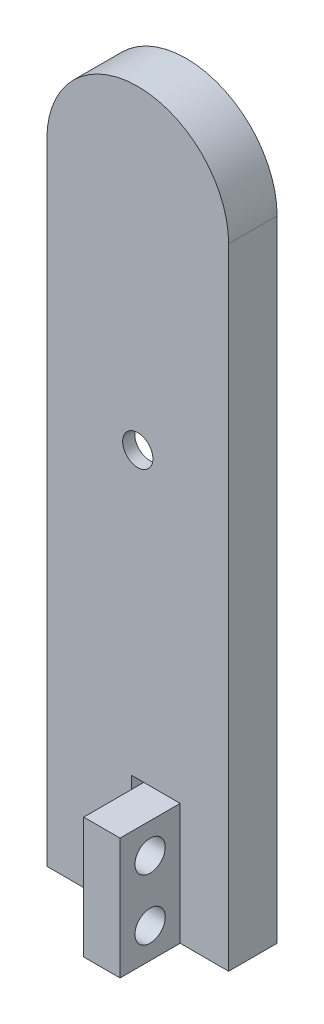
from build123d import *

# Parameters (mm, degrees)
EXTRUDE_1_DEPTH     = 4
CUT_EXTRUDE_1_DEPTH = 3
SKETCH_5_R          = 1.25
CUT_EXTRUDE_2_DEPTH = 12.4
SKETCH_6_W          = 1
SKETCH_6_H          = 10
CUT_EXTRUDE_3_DEPTH = 16.3
SKETCH_9_W          = 5
SKETCH_9_H          = 10
EXTRUDE_4_DEPTH     = 3
SKETCH_10_R         = 1.25
CUT_EXTRUDE_4_DEPTH = 5.1


with BuildPart() as part:
    # 草圖1 → 填料-伸長1 (new body)
    with BuildSketch(Plane.XY):
        with BuildLine():
            Line((7.5, 0), (7.5, 52))
            ThreePointArc((7.5, 52), (0, 59.5), (-7.5, 52))
            Line((-7.5, 52), (-7.5, 0))
            Line((-7.5, 0), (7.5, 0))
        make_face()
    extrude(amount=EXTRUDE_1_DEPTH)

    # 草圖3 → 除料-伸長1 (cut)
    with BuildSketch(Plane.XY):
        with BuildLine():
            ThreePointArc((-2.5, 48.75876512), (0, 51.25876512), (2.5, 48.75876512))
            Line((2.5, 48.75876512), (5, 33.5))
            Line((5, 33.5), (2.467939071, 17.842139978))
            ThreePointArc((2.467939071, 17.842139978), (-0.200190311, 15.749263002), (-2.5, 18.24123488))
            Line((-2.5, 18.24123488), (-5, 33.5))
            Line((-5, 33.5), (-2.5, 48.75876512))
        make_face()
    extrude(amount=CUT_EXTRUDE_1_DEPTH, mode=Mode.SUBTRACT)

    # 草圖5 → 除料-伸長2 (cut)
    with BuildSketch(Plane.XY):
        with Locations((0, 33.5)):
            Circle(SKETCH_5_R)
    extrude(amount=CUT_EXTRUDE_2_DEPTH, mode=Mode.SUBTRACT)

    # 草圖6 → 除料-伸長3 (cut)
    with BuildSketch(Plane.XY):
        with Locations((0, 5)):
            Rectangle(SKETCH_6_W, SKETCH_6_H)
    extrude(amount=CUT_EXTRUDE_3_DEPTH, mode=Mode.SUBTRACT)

    # 草圖9 → 填料-伸長4 (add)
    with BuildSketch(Plane(origin=(0.5, 0, 0), x_dir=(0, 0, -1), z_dir=(1, 0, 0))):
        with Locations((-6.46178466, 5)):
            Rectangle(SKETCH_9_W, SKETCH_9_H)
    extrude(amount=EXTRUDE_4_DEPTH)

    # 草圖10 → 除料-伸長4 (cut)
    with BuildSketch(Plane(origin=(0.5, 0, 0), x_dir=(0, 0, -1), z_dir=(1, 0, 0))):
        with Locations((-6.48089233, 7.5)):
            Circle(SKETCH_10_R)
        with Locations((-6.48089233, 2.5)):
            Circle(SKETCH_10_R)
    extrude(amount=CUT_EXTRUDE_4_DEPTH, mode=Mode.SUBTRACT)


solid = part.part
